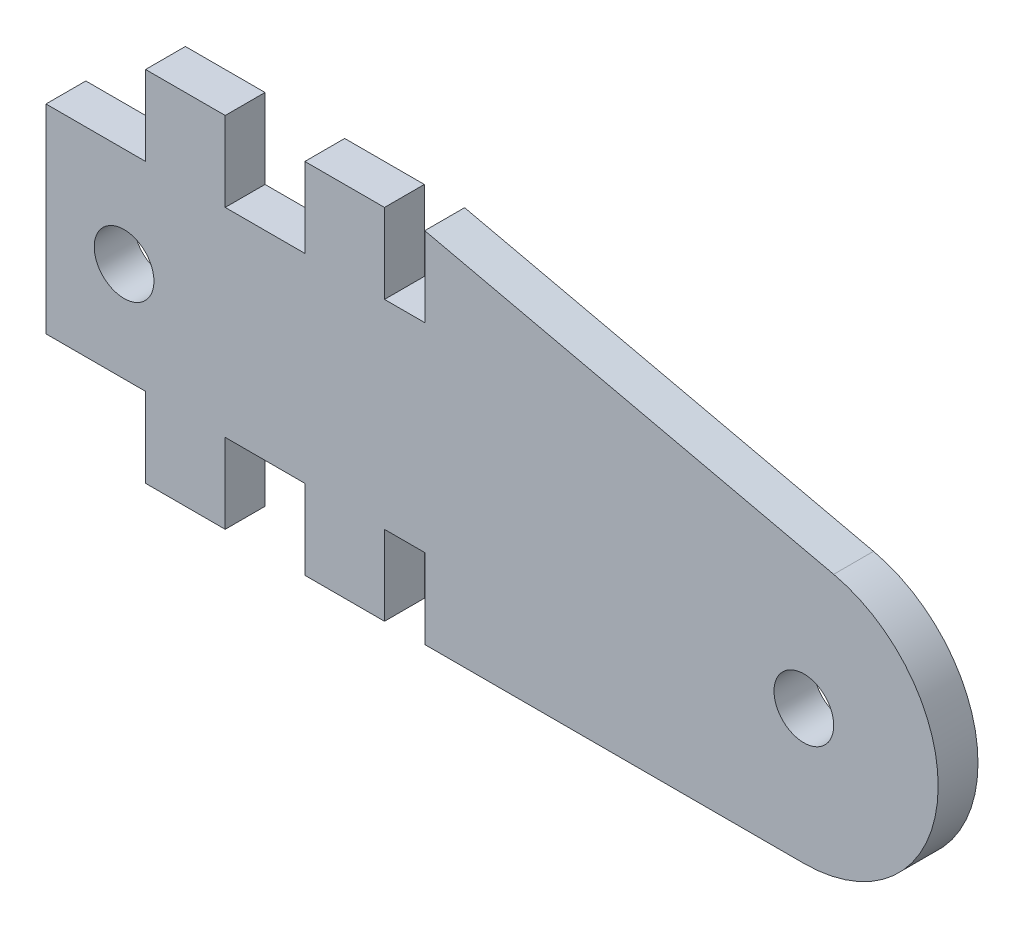
from build123d import *

# Parameters (mm, degrees)
SKETCH1_R           = 1.5
BOSS_EXTRUDE1_DEPTH = 2


with BuildPart() as part:
    # Sketch1 → Boss-Extrude1 (new body)
    with BuildSketch(Plane.XY):
        with BuildLine():
            Line((5, 0), (9, 0))
            Line((9, 0), (9, 4))
            Line((9, 4), (13, 4))
            Line((13, 4), (13, 0))
            Line((13, 0), (17, 0))
            Line((17, 0), (17, 4))
            Line((17, 4), (19.021561934, 4))
            Line((19.021561934, 4), (19.021561934, 0))
            Line((19.021561934, 0), (38.059495851, 0))
            ThreePointArc((38.059495851, 0), (44.762590659, 5.991570372), (39.557599026, 13.322222296))
            Line((39.557599026, 13.322222296), (19.021561934, 17.999988357))
            Line((19.021561934, 17.999988357), (19.021561934, 13.999988357))
            Line((19.021561934, 13.999988357), (17, 13.999988357))
            Line((17, 13.999988357), (17, 17.999988357))
            Line((17, 17.999988357), (13, 17.999988357))
            Line((13, 17.999988357), (13, 13.999988357))
            Line((13, 13.999988357), (9, 13.999988357))
            Line((9, 13.999988357), (9, 17.999988357))
            Line((9, 17.999988357), (5, 17.999988357))
            Line((5, 17.999988357), (5, 13.999988357))
            Line((5, 13.999988357), (0, 13.999988357))
            Line((0, 13.999988357), (0, 4))
            Line((0, 4), (5, 4))
            Line((5, 4), (5, 0))
        make_face()
        with Locations((3.920490093, 9)):
            Circle(SKETCH1_R, mode=Mode.SUBTRACT)
        with Locations((38.059495851, 6.745343083)):
            Circle(SKETCH1_R, mode=Mode.SUBTRACT)
    extrude(amount=BOSS_EXTRUDE1_DEPTH)


solid = part.part
